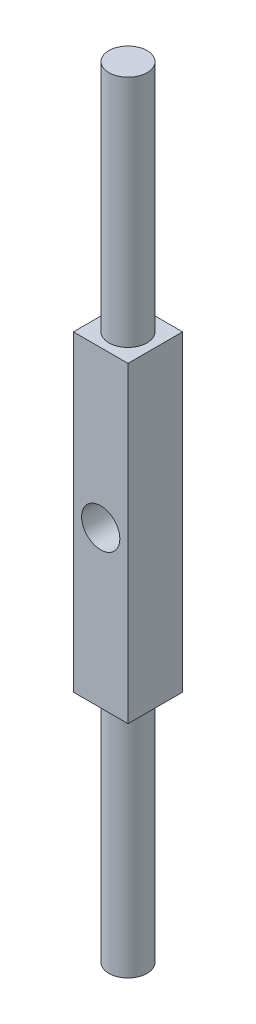
from build123d import *

# Parameters (mm, degrees)
SKETCH1_R           = 2.45
BOSS_EXTRUDE1_DEPTH = 50
BOSS_EXTRUDE2_START = -50
SKETCH1_2_R         = 2.45
BOSS_EXTRUDE2_DEPTH = 50
SKETCH2_W           = 7
SKETCH2_H           = 7
BOSS_EXTRUDE3_DEPTH = 20
SKETCH2_2_W         = 7
SKETCH2_2_H         = 7
BOSS_EXTRUDE4_DEPTH = 20
SKETCH3_R           = 2.45
CUT_EXTRUDE1_DEPTH  = 51.608793702


with BuildPart() as part:
    # Sketch1 → Boss-Extrude1 (new body)
    with BuildSketch(Plane(origin=(0, 0, 0), x_dir=(1, 0, 0), z_dir=(0, 1, 0))):
        Circle(SKETCH1_R)
    extrude(amount=BOSS_EXTRUDE1_DEPTH)

    # Sketch1_2 → Boss-Extrude2 (add)
    with BuildSketch(Plane(origin=(0, 0, 0), x_dir=(1, 0, 0), z_dir=(0, 1, 0)).offset(BOSS_EXTRUDE2_START)):
        Circle(SKETCH1_2_R)
    extrude(amount=BOSS_EXTRUDE2_DEPTH)

    # Sketch2 → Boss-Extrude3 (add)
    with BuildSketch(Plane(origin=(0, 0, 0), x_dir=(1, 0, 0), z_dir=(0, 1, 0))):
        Rectangle(SKETCH2_W, SKETCH2_H)
    extrude(amount=BOSS_EXTRUDE3_DEPTH)

    # Sketch2_2 → Boss-Extrude4 (add)
    with BuildSketch(Plane(origin=(0, 0, 0), x_dir=(1, 0, 0), z_dir=(0, 1, 0))):
        Rectangle(SKETCH2_2_W, SKETCH2_2_H)
    extrude(amount=-BOSS_EXTRUDE4_DEPTH)

    # Sketch3 → Cut-Extrude1 (cut, through all)
    with BuildSketch(Plane.XY.offset(3.5)):
        Circle(SKETCH3_R)
    extrude(amount=-CUT_EXTRUDE1_DEPTH, mode=Mode.SUBTRACT)


solid = part.part
